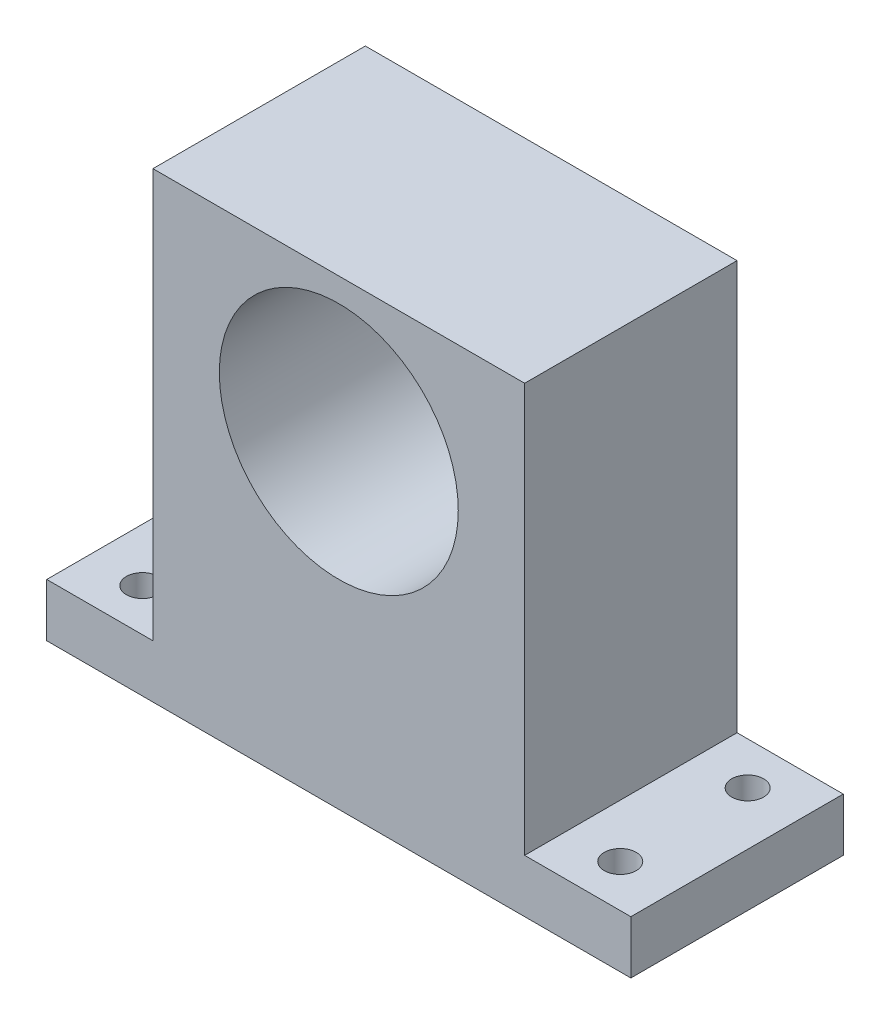
from build123d import *

# Parameters (mm, degrees)
SKETCH_1_W          = 35
SKETCH_1_H          = 43.5
EXTRUDE_1_DEPTH     = 20
SKETCH_2_W          = 20
SKETCH_2_H          = 5
EXTRUDE_2_DEPTH     = 10
SKETCH_3_W          = 20
SKETCH_3_H          = 5
EXTRUDE_3_DEPTH     = 10
SKETCH_4_R          = 1.5
CUT_EXTRUDE_2_DEPTH = 5
SKETCH_5_R          = 11.25
CUT_EXTRUDE_4_DEPTH = 20


with BuildPart() as part:
    # Эскиз1 → Бобышка-Вытянуть1 (new body)
    with BuildSketch(Plane.XY):
        Rectangle(SKETCH_1_W, SKETCH_1_H)
    extrude(amount=EXTRUDE_1_DEPTH)

    # Эскиз2 → Бобышка-Вытянуть2 (add)
    with BuildSketch(Plane(origin=(17.5, 0, 0), x_dir=(0, 0, -1), z_dir=(1, 0, 0))):
        with Locations((-10, -19.25)):
            Rectangle(SKETCH_2_W, SKETCH_2_H)
    extrude(amount=EXTRUDE_2_DEPTH)

    # Эскиз3 → Бобышка-Вытянуть3 (add)
    with BuildSketch(Plane.ZY.offset(17.5)):
        with Locations((10, -19.25)):
            Rectangle(SKETCH_3_W, SKETCH_3_H)
    extrude(amount=EXTRUDE_3_DEPTH)

    # Эскиз4 → Вырез-Вытянуть2 (cut)
    with BuildSketch(Plane(origin=(0, -16.75, 0), x_dir=(1, 0, 0), z_dir=(0, 1, 0))):
        with Locations((-22.5, -16)):
            Circle(SKETCH_4_R)
        with Locations((-22.5, -4)):
            Circle(SKETCH_4_R)
        with Locations((22.5, -16)):
            Circle(SKETCH_4_R)
        with Locations((22.5, -4)):
            Circle(SKETCH_4_R)
    extrude(amount=-CUT_EXTRUDE_2_DEPTH, mode=Mode.SUBTRACT)

    # Эскиз5 → Вырез-Вытянуть4 (cut)
    with BuildSketch(Plane(origin=(0, 0, 0), x_dir=(-1, 0, 0), z_dir=(0, 0, -1))):
        with Locations((0, 8.25)):
            Circle(SKETCH_5_R)
    extrude(amount=-CUT_EXTRUDE_4_DEPTH, mode=Mode.SUBTRACT)


solid = part.part
